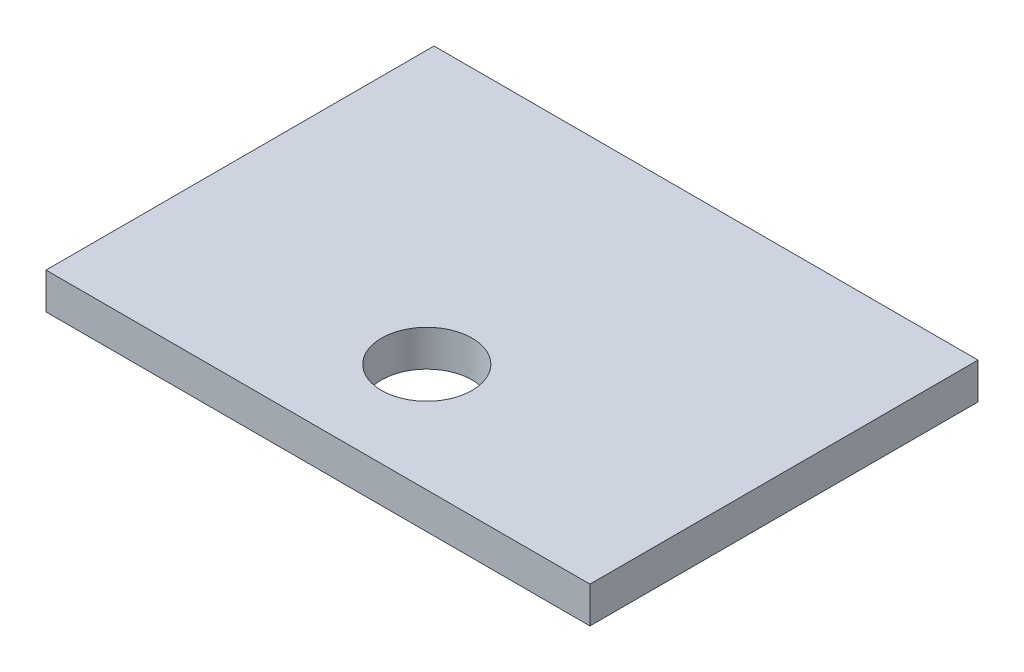
from build123d import *

# Parameters (mm, degrees)
SKETCH_1_W      = 15
SKETCH_1_H      = 10.7
SKETCH_1_R      = 1.25
EXTRUDE_1_DEPTH = 1


with BuildPart() as part:
    # 草图1 → 凸台-拉伸1 (new body)
    with BuildSketch(Plane(origin=(0, 0, 0), x_dir=(1, 0, 0), z_dir=(0, 1, 0))):
        Rectangle(SKETCH_1_W, SKETCH_1_H)
        with Locations((0, -2.35)):
            Circle(SKETCH_1_R, mode=Mode.SUBTRACT)
    extrude(amount=EXTRUDE_1_DEPTH)


solid = part.part
